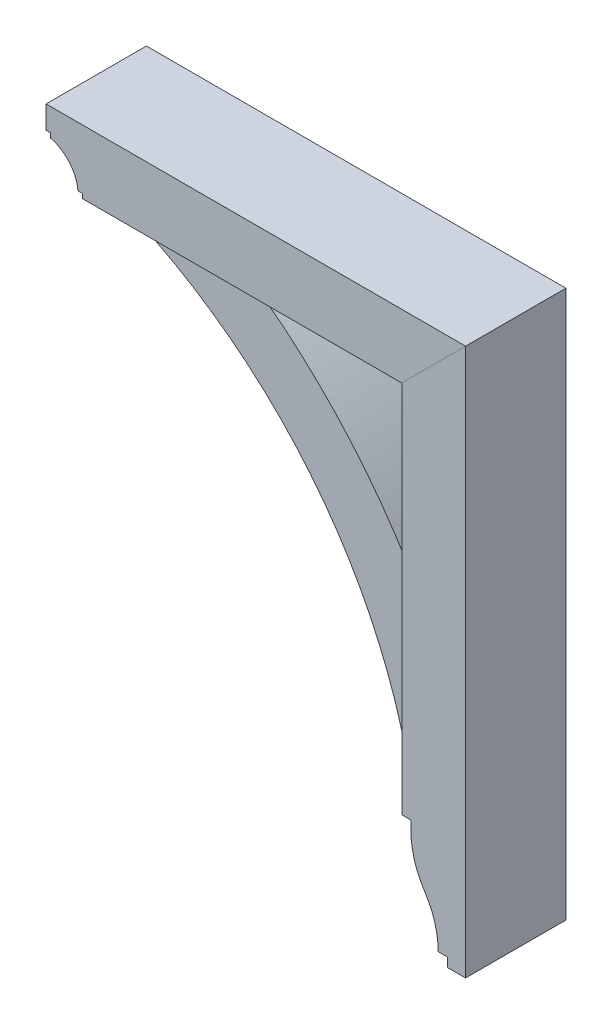
from build123d import *

# Parameters (mm, degrees)
BOSS_EXTRUDE1_DEPTH = 69.85
BOSS_EXTRUDE2_DEPTH = 44.45
BOSS_EXTRUDE3_DEPTH = 69.85


with BuildPart() as part:
    # Sketch1 → Boss-Extrude1 (new body, symmetric)
    with BuildSketch(Plane.XY):
        with BuildLine():
            Line((-254.768776984, 387.985), (-254.768776984, 394.335))
            Line((-254.768776984, 394.335), (-261.118776984, 394.335))
            Line((-261.118776984, 394.335), (-261.118776984, 426.085))
            Line((-261.118776984, 426.085), (323.081223016, 426.085))
            Line((323.081223016, 426.085), (234.181223016, 337.185))
            Line((234.181223016, 337.185), (-210.318776984, 337.185))
            Line((-210.318776984, 337.185), (-210.318776984, 343.535))
            Line((-210.318776984, 343.535), (-216.668776984, 343.535))
            ThreePointArc((-216.668776984, 343.535), (-228.660423906, 371.810016924), (-254.768776984, 387.985))
        make_face()
    extrude(amount=BOSS_EXTRUDE1_DEPTH, both=True)


with BuildPart() as body_2:
    # Sketch1_3 → Boss-Extrude2 (new body, symmetric)
    with BuildSketch(Plane.XY):
        with BuildLine():
            ThreePointArc((234.181223016, 67.31), (128.407804757, 216.350798568), (-8.706276984, 337.185))
            Line((-8.706276984, 337.185), (-134.118776984, 337.185))
            Line((-134.118776984, 337.185), (-134.118776984, 311.785))
            ThreePointArc((-134.118776984, 311.785), (81.562882665, 138.424539713), (208.781223016, -107.315))
            Line((208.781223016, -107.315), (234.181223016, -107.315))
            Line((234.181223016, -107.315), (234.181223016, 67.31))
        make_face()
    extrude(amount=BOSS_EXTRUDE2_DEPTH, both=True)


with BuildPart() as body_3:
    # Sketch1_4 → Boss-Extrude3 (new body, symmetric)
    with BuildSketch(Plane.XY):
        with BuildLine():
            Line((323.081223016, -335.915), (323.081223016, 426.085))
            Line((323.081223016, 426.085), (234.181223016, 337.185))
            Line((234.181223016, 337.185), (234.181223016, -183.515))
            Line((234.181223016, -183.515), (246.881223016, -183.515))
            Line((246.881223016, -183.515), (246.881223016, -196.215))
            ThreePointArc((246.881223016, -196.215), (251.768629387, -229.515028089), (266.018608337, -260.006284404))
            ThreePointArc((266.018608337, -260.006284404), (280.138450492, -290.219081757), (284.981223016, -323.215))
            Line((284.981223016, -323.215), (297.681223016, -323.215))
            Line((297.681223016, -323.215), (297.681223016, -335.915))
            Line((297.681223016, -335.915), (323.081223016, -335.915))
        make_face()
    extrude(amount=BOSS_EXTRUDE3_DEPTH, both=True)


solid = Compound([part.part, body_2.part, body_3.part])
